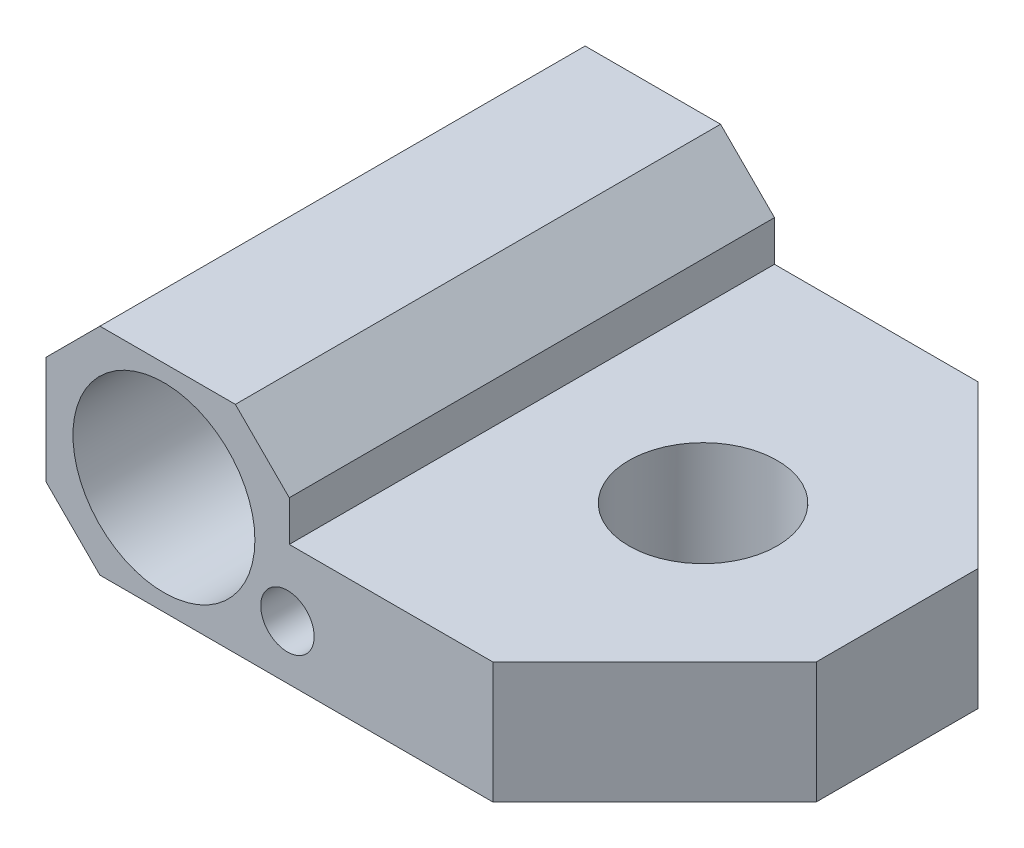
from build123d import *

# Parameters (mm, degrees)
BOSS_EXTRUDE1_DEPTH      = 4
BOSS_EXTRUDE1_DEPTH_BACK = 4
SKETCH1_W                = 22.575
SKETCH1_H                = 18
SKETCH1_R                = 2.75
SKETCH3_R                = 3.375
SKETCH3_R_2              = 0.9905
CUT_EXTRUDE1_DEPTH       = 25.008136642
SKETCH4_W                = 13.55
SKETCH4_H                = 3.5
CUT_EXTRUDE2_DEPTH       = 25.008136642
CUT_EXTRUDE3_DEPTH       = 19.375
CHAMFER1_SIZE            = 2


with BuildPart() as part:
    # Sketch1 → Boss-Extrude1 (new, two sides: drawn at the far end of the back side and taken through both)
    with BuildSketch(Plane(origin=(0, 0, 0), x_dir=(1, 0, 0), z_dir=(0, 1, 0)).offset(-BOSS_EXTRUDE1_DEPTH_BACK)):
        with Locations((-4.0875, 0)):
            Rectangle(SKETCH1_W, SKETCH1_H)
        Circle(SKETCH1_R, mode=Mode.SUBTRACT)
    extrude(amount=BOSS_EXTRUDE1_DEPTH + BOSS_EXTRUDE1_DEPTH_BACK)

    # Sketch3 → Cut-Extrude1 (cut, through all)
    with BuildSketch(Plane.XY.offset(9)):
        with Locations((-11, 0)):
            Circle(SKETCH3_R)
        with Locations((-6.417424305, -2)):
            Circle(SKETCH3_R_2)
    extrude(amount=-CUT_EXTRUDE1_DEPTH, mode=Mode.SUBTRACT)

    # Sketch4 → Cut-Extrude2 (cut, through all)
    with BuildSketch(Plane.XY.offset(9)):
        with Locations((0.425, 2.25)):
            Rectangle(SKETCH4_W, SKETCH4_H)
    extrude(amount=-CUT_EXTRUDE2_DEPTH, mode=Mode.SUBTRACT)

    # Sketch5 → Cut-Extrude3 (cut, through all)
    with BuildSketch(Plane(origin=(0, 0.5, 0), x_dir=(-1, 0, 0), z_dir=(0, 1, 0))):
        Polygon((-1.2, -9), (-7.2, -3), (-7.2, -9), align=None)
        Polygon((-1.2, 9), (-7.2, 3), (-7.2, 9), align=None)
    extrude(amount=-CUT_EXTRUDE3_DEPTH, mode=Mode.SUBTRACT)

    # Chamfer1
    chamfer1_edges = [part.edges().sort_by_distance(p)[0] for p in [
        (-15.375, -4, 0),
        (-15.375, 4, 0),
        (-6.35, 4, 0),
    ]]
    chamfer(chamfer1_edges, length=CHAMFER1_SIZE)


solid = part.part
